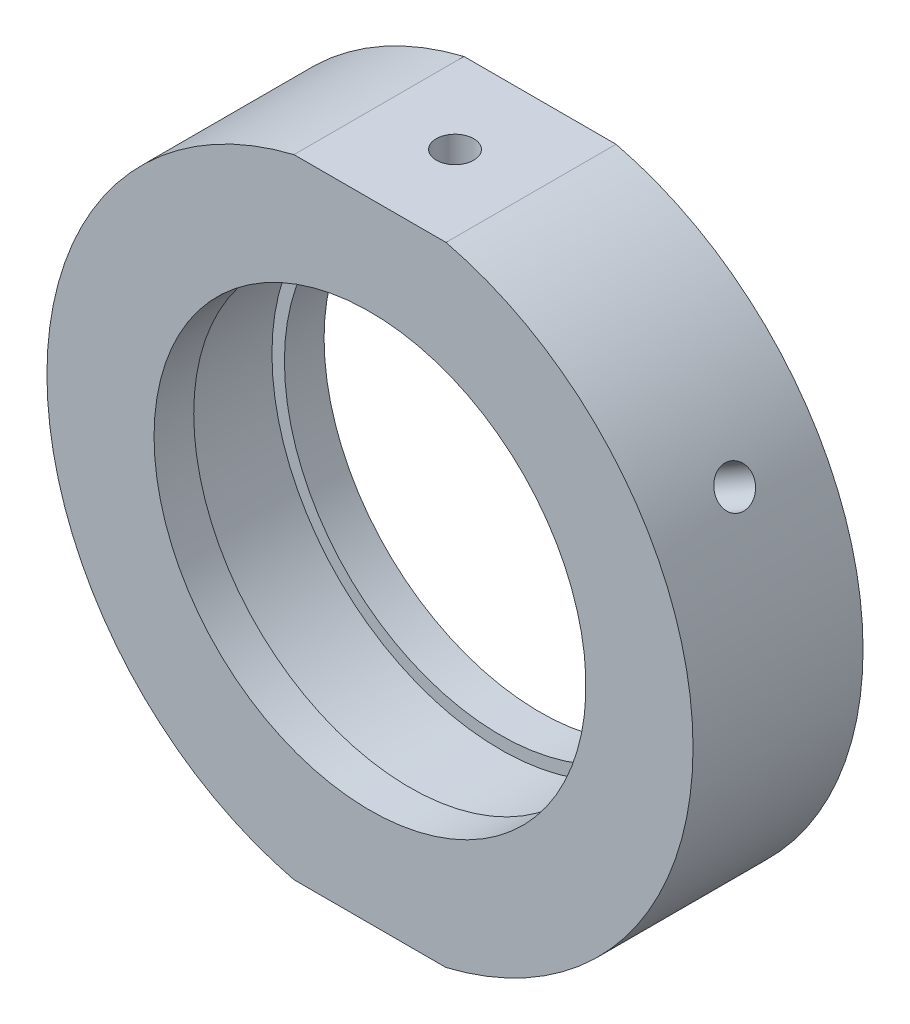
from build123d import *

# Parameters (mm, degrees)
SKETCH_2_W                       = 64.02174429
SKETCH_2_H                       = 9.248919907
CUT_EXTRUDE_1_DEPTH              = 49
HOLE_WIZARD_M4_2_D               = 3.3
HOLE_WIZARD_M4_2_DEPTH           = 5.5
HOLE_WIZARD_M4_2_TIP             = 0.991420021
HOLE_WIZARD_M6_2_D               = 5
HOLE_WIZARD_M6_2_DEPTH           = 5.5
HOLE_WIZARD_M6_2_TIP             = 1.502151548
HOLE_WIZARD_M4_3_D               = 3.3
HOLE_WIZARD_M4_3_DEPTH           = 13.4
HOLE_WIZARD_M4_3_TIP             = 0.991420021
HOLE_WIZARD_M4_3_ON_FACE_2_D     = 3.3
HOLE_WIZARD_M4_3_ON_FACE_2_DEPTH = 13.4
HOLE_WIZARD_M4_3_ON_FACE_2_TIP   = 0.991420021


with BuildPart() as part:
    # 草图1 → 旋转1 (revolve)
    with BuildSketch(Plane(origin=(0, 0, 0), x_dir=(1, 0, 0), z_dir=(0, 1, 0)), mode=Mode.PRIVATE) as revolve_1_sk:
        Polygon((28.5, 7.5), (28.5, -7.5), (19.05, -7.5), (19.05, -4), (20.15, -4), (20.15, 4), (19.05, 4), (19.05, 7.5), align=None)
    revolve(revolve_1_sk.sketch.rotate(Axis((0, 0, -31.9390681), (0, 0, 1)), 180), axis=Axis((0, 0, -31.9390681), (0, 0, 1)))  # turned: the seam where the file's is

    # 草图2 → 切除-拉伸1 (cut)
    with BuildSketch(Plane.XY.offset(7.5)):
        with Locations((-1.141100508, 32.324459954)):
            Rectangle(SKETCH_2_W, SKETCH_2_H)
        with Locations((-1.141100508, -32.324459954)):
            Rectangle(SKETCH_2_W, SKETCH_2_H)
    extrude(amount=-CUT_EXTRUDE_1_DEPTH, mode=Mode.SUBTRACT)

    # M4 螺纹孔2
    with Locations(Plane(origin=(0, 27.7, 0), x_dir=(1, 0, 0), z_dir=(0, 1, 0))):
        with Locations((0, 0)):
            Hole(HOLE_WIZARD_M4_2_D / 2, depth=HOLE_WIZARD_M4_2_DEPTH)
            with Locations((0, 0, -(HOLE_WIZARD_M4_2_DEPTH + HOLE_WIZARD_M4_2_TIP / 2))):  # 118° drill point
                Cone(0, HOLE_WIZARD_M4_2_D / 2, HOLE_WIZARD_M4_2_TIP, mode=Mode.SUBTRACT)

    # M6 螺纹孔2
    with Locations(Plane(origin=(0, -27.7, 0), x_dir=(-1, 0, 0), z_dir=(0, -1, 0))):
        with Locations((0, 0)):
            Hole(HOLE_WIZARD_M6_2_D / 2, depth=HOLE_WIZARD_M6_2_DEPTH)
            with Locations((0, 0, -(HOLE_WIZARD_M6_2_DEPTH + HOLE_WIZARD_M6_2_TIP / 2))):  # 118° drill point
                Cone(0, HOLE_WIZARD_M6_2_D / 2, HOLE_WIZARD_M6_2_TIP, mode=Mode.SUBTRACT)

    # M4 螺纹孔3
    with Locations(Plane(origin=(24.681724008, 14.25, 0), x_dir=(-0.5, 0.866025404, 0), z_dir=(0.866025404, 0.5, 0))):
        with Locations((0, 0)):
            Hole(HOLE_WIZARD_M4_3_D / 2, depth=HOLE_WIZARD_M4_3_DEPTH)
            with Locations((0, 0, -(HOLE_WIZARD_M4_3_DEPTH + HOLE_WIZARD_M4_3_TIP / 2))):  # 118° drill point
                Cone(0, HOLE_WIZARD_M4_3_D / 2, HOLE_WIZARD_M4_3_TIP, mode=Mode.SUBTRACT)

    # M4 螺纹孔3 on face 2
    with Locations(Plane(origin=(-24.681724008, 14.25, 0), x_dir=(-0.500000175, -0.866025303, 0), z_dir=(-0.866025303, 0.500000175, 0))):
        with Locations((0, 0)):
            Hole(HOLE_WIZARD_M4_3_ON_FACE_2_D / 2, depth=HOLE_WIZARD_M4_3_ON_FACE_2_DEPTH)
            with Locations((0, 0, -(HOLE_WIZARD_M4_3_ON_FACE_2_DEPTH + HOLE_WIZARD_M4_3_ON_FACE_2_TIP / 2))):  # 118° drill point
                Cone(0, HOLE_WIZARD_M4_3_ON_FACE_2_D / 2, HOLE_WIZARD_M4_3_ON_FACE_2_TIP, mode=Mode.SUBTRACT)


solid = part.part
